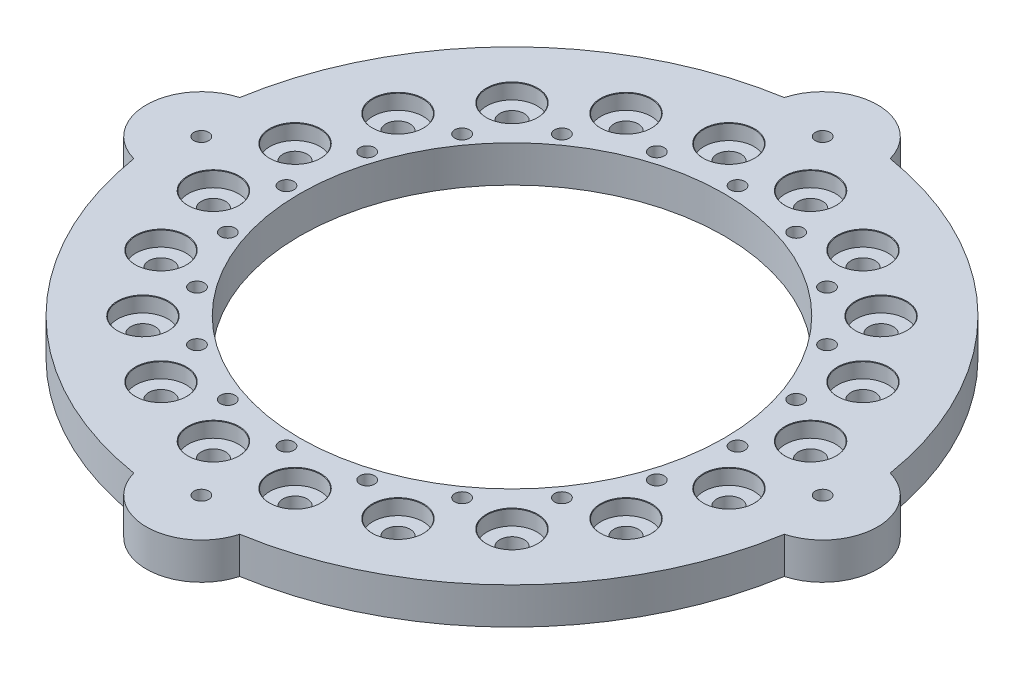
from build123d import *

# Parameters (mm, degrees)
SKETCH3_R               = 114.3
SKETCH3_R_2             = 73.533
BOSS_EXTRUDE1_DEPTH     = 12.7
SKETCH16_R              = 19.05
BOSS_EXTRUDE2_DEPTH     = 12.7
CIRPATTERN6_COUNT       = 4
CIRPATTERN2_COUNT       = 20
F_1_4_20_TAPPED_HOLE2_D = 5.1054
CIRPATTERN4_COUNT       = 20
F_1_4_20_TAPPED_HOLE3_D = 5.1054


with BuildPart() as part:
    # Sketch3 → Boss-Extrude1 (new body)
    with BuildSketch(Plane(origin=(0, 0, 0), x_dir=(1, 0, 0), z_dir=(0, 1, 0))):
        Circle(SKETCH3_R)
        Circle(SKETCH3_R_2, mode=Mode.SUBTRACT)
    extrude(amount=BOSS_EXTRUDE1_DEPTH)

    # Sketch16 → Boss-Extrude2 (add)
    with BuildSketch(Plane(origin=(0, 12.7, 0), x_dir=(1, 0, 0), z_dir=(0, 1, 0))):
        with Locations((107.763073453, 0)):
            Circle(SKETCH16_R)
    boss_extrude2 = extrude(amount=-BOSS_EXTRUDE2_DEPTH)

    # CirPattern6: Boss-Extrude2 ×4 about axis
    cirpattern6_axis = Axis((0, 12.7, 0), (0, -1, 0))
    for i in range(1, CIRPATTERN6_COUNT):
        add(boss_extrude2.rotate(cirpattern6_axis, i * 360 / CIRPATTERN6_COUNT))

    # Sketch8 → CBORE for 5_16 Binding Head Machine Scre (revolve, cut)
    with BuildSketch(Plane(origin=(89.411079645, 12.7, -14.161323808), x_dir=(0, 0, 1), z_dir=(1, 0, 0))):
        Polygon((0, 0), (0, 12.7), (4.2164, 12.7), (4.2164, 5.3086), (8.73125, 5.3086), (8.73125, 0.15875), (8.89, 0), align=None)
    cbore_for_5_16_binding_head_machine_scre = revolve(axis=Axis((89.411079645, 19.05, -14.161323808), (0, -1, 0)), mode=Mode.SUBTRACT)

    # CirPattern2: CBORE for 5_16 Binding Head Machine Scre ×20 about axis
    cirpattern2_axis = Axis((0, 12.7, 0), (0, -1, 0))
    for i in range(1, CIRPATTERN2_COUNT):
        add(cbore_for_5_16_binding_head_machine_scre.rotate(cirpattern2_axis, i * 360 / CIRPATTERN2_COUNT), mode=Mode.SUBTRACT)

    # 1_4-20 Tapped Hole2 (through all)
    with Locations(Plane(origin=(0, 12.7, 0), x_dir=(1, 0, 0), z_dir=(0, 1, 0))):
        with Locations((78.232, 0)):
            f_1_4_20_tapped_hole2 = Hole(F_1_4_20_TAPPED_HOLE2_D / 2)

    # CirPattern4: 1_4-20 Tapped Hole2 ×20 about axis
    cirpattern4_axis = Axis((0, 12.7, 0), (0, -1, 0))
    for i in range(1, CIRPATTERN4_COUNT):
        add(f_1_4_20_tapped_hole2.rotate(cirpattern4_axis, i * 360 / CIRPATTERN4_COUNT), mode=Mode.SUBTRACT)

    # 1_4-20 Tapped Hole3 (through all)
    with Locations(Plane(origin=(0, 12.7, 0), x_dir=(1, 0, 0), z_dir=(0, 1, 0))):
        with Locations((107.763073453, 0), (0, -107.763073453), (-107.763073453, 0), (0, 107.763073453)):
            Hole(F_1_4_20_TAPPED_HOLE3_D / 2)


solid = part.part
